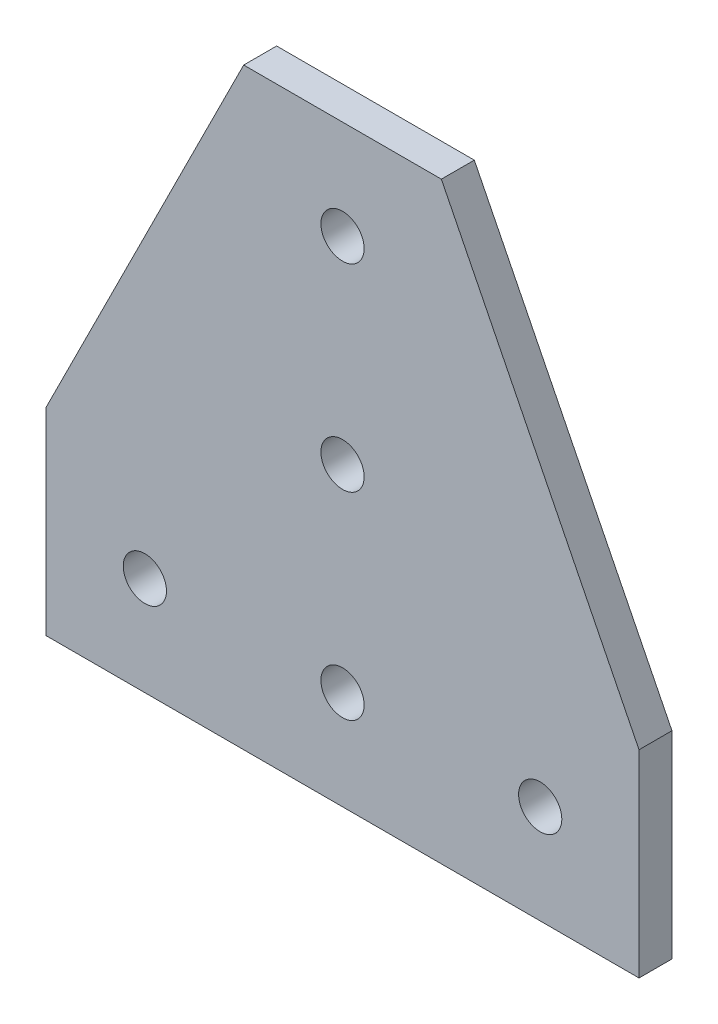
from build123d import *

# Parameters (mm, degrees)
SKETCH1_R           = 4.1656
BOSS_EXTRUDE1_DEPTH = 3.175


with BuildPart() as part:
    # Sketch1 → Boss-Extrude1 (new body, symmetric)
    with BuildSketch(Plane.XY):
        Polygon((0, 0), (0, 38.1), (38.1, 114.3), (76.2, 114.3), (114.3, 38.1), (114.3, 0), align=None)
        with Locations((19.05, 19.05)):
            Circle(SKETCH1_R, mode=Mode.SUBTRACT)
        with Locations((57.15, 19.05)):
            Circle(SKETCH1_R, mode=Mode.SUBTRACT)
        with Locations((95.25, 19.05)):
            Circle(SKETCH1_R, mode=Mode.SUBTRACT)
        with Locations((57.15, 57.15)):
            Circle(SKETCH1_R, mode=Mode.SUBTRACT)
        with Locations((57.15, 95.25)):
            Circle(SKETCH1_R, mode=Mode.SUBTRACT)
    extrude(amount=BOSS_EXTRUDE1_DEPTH, both=True)


solid = part.part
